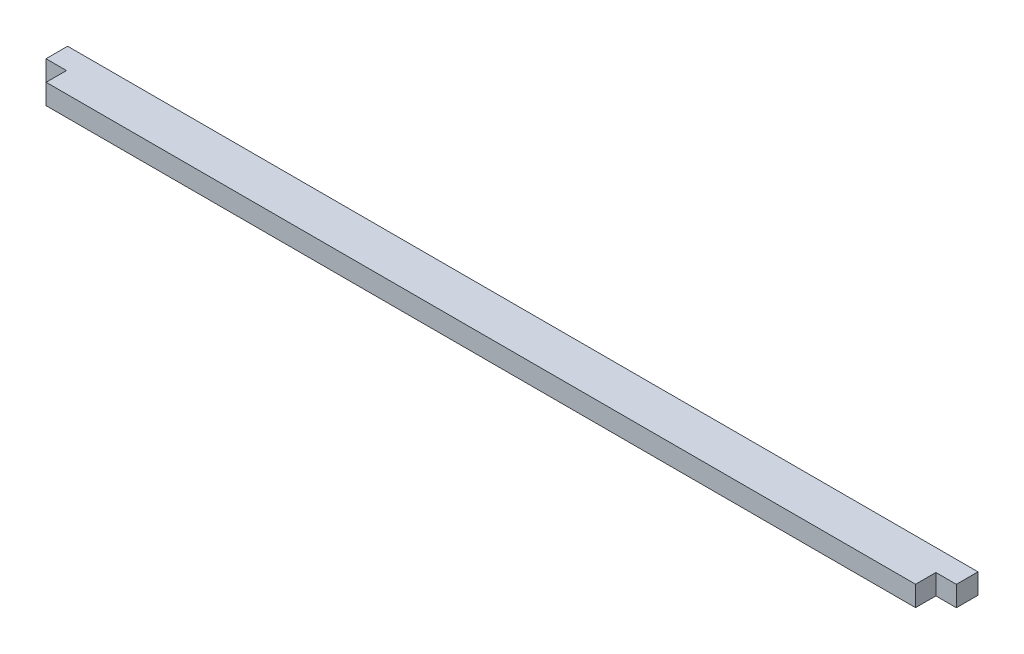
from build123d import *

# Parameters (mm, degrees)
BOSS_EXTRUDE1_DEPTH = 3.175
BOSS_EXTRUDE3_DEPTH = 3.175


with BuildPart() as part:
    # Sketch2 → Boss-Extrude1 (new body)
    with BuildSketch(Plane(origin=(0, 0, 0), x_dir=(1, 0, 0), z_dir=(0, 1, 0))):
        Polygon((3.2004, -6.35), (138.79195, -6.35), (138.79195, -3.175), (141.99235, -3.175), (141.99235, 0), (0, 0), (0, -3.175), (3.2004, -3.175), align=None)
    extrude(amount=BOSS_EXTRUDE1_DEPTH)

    # Sketch4 → Boss-Extrude3 (add)
    with BuildSketch(Plane(origin=(0, 3.175, 0), x_dir=(1, 0, 0), z_dir=(0, 1, 0))):
        Polygon((142.09395, -3.2766), (142.09395, 0.1016), (-0.1016, 0.1016), (-0.1016, -3.2766), (3.0988, -3.2766), (3.0988, -6.4516), (138.89355, -6.4516), (138.89355, -3.2766), align=None)
    extrude(amount=-BOSS_EXTRUDE3_DEPTH)


solid = part.part
